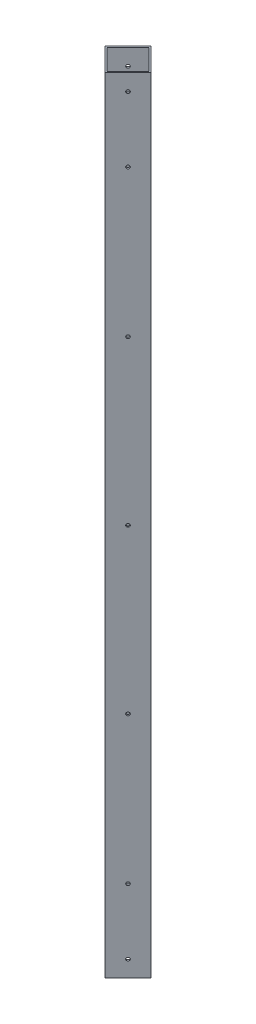
from build123d import *

# Parameters (mm, degrees)
EXTRUDE_1_DEPTH     = 240
SKETCH_3_R          = 1
CUT_EXTRUDE_1_DEPTH = 31
SKETCH_4_R          = 1
CUT_EXTRUDE_2_DEPTH = 31


with BuildPart() as part:
    # 草图1 → 凸台-拉伸1 (new body, symmetric)
    with BuildSketch(Plane(origin=(0, 0, 0), x_dir=(1, 0, 0), z_dir=(0, 1, 0))):
        Polygon((14.142135624, 0), (0, 14.142135624), (-14.142135624, 0), (0, -14.142135624), align=None)
        Polygon((12.727922061, 0), (0, 12.727922061), (-12.727922061, 0), (0, -12.727922061), align=None, mode=Mode.SUBTRACT)
    extrude(amount=EXTRUDE_1_DEPTH, both=True)

    # 草图3 → 切除-拉伸1 (cut, through all)
    with BuildSketch(Plane(origin=(7.071067812, 0, 7.071067812), x_dir=(0.707106781, 0, -0.707106781), z_dir=(0.707106781, 0, 0.707106781))):
        with Locations((0, 230)):
            Circle(SKETCH_3_R)
        with Locations((0, 190)):
            Circle(SKETCH_3_R)
        with Locations((0, -190)):
            Circle(SKETCH_3_R)
        with Locations((0, -230)):
            Circle(SKETCH_3_R)
    extrude(amount=-CUT_EXTRUDE_1_DEPTH, mode=Mode.SUBTRACT)

    # 草图4 → 切除-拉伸2 (cut, through all)
    with BuildSketch(Plane(origin=(7.071067812, 0, 7.071067812), x_dir=(0.707106781, 0, -0.707106781), z_dir=(0.707106781, 0, 0.707106781))):
        with Locations((0, 100)):
            Circle(SKETCH_4_R)
        Circle(SKETCH_4_R)
        with Locations((0, -100)):
            Circle(SKETCH_4_R)
    extrude(amount=-CUT_EXTRUDE_2_DEPTH, mode=Mode.SUBTRACT)


solid = part.part
